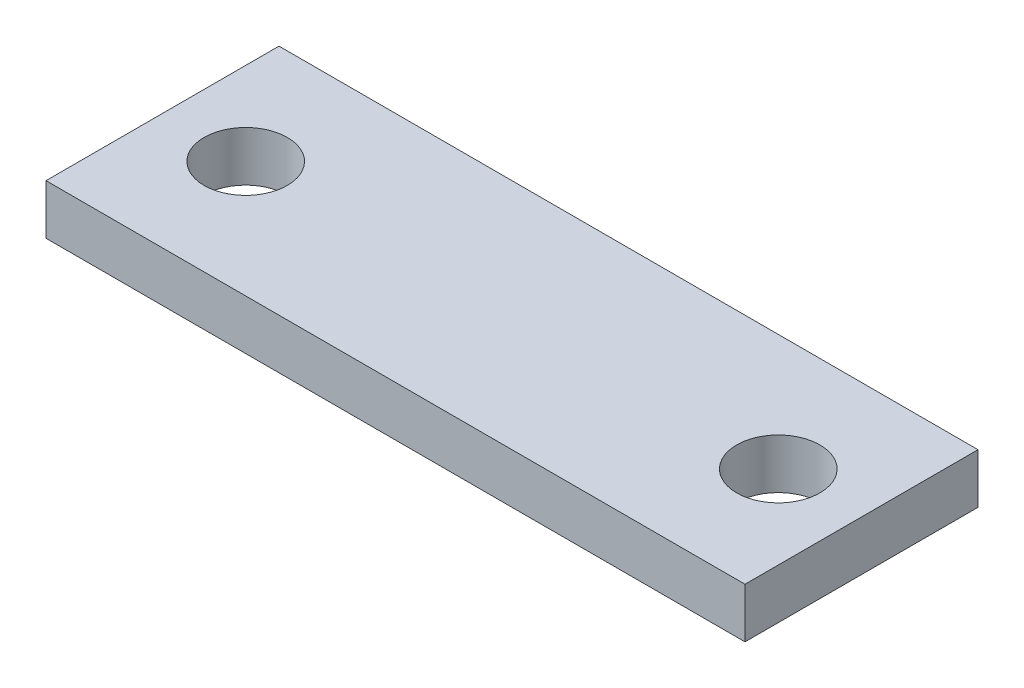
from build123d import *

# Parameters (mm, degrees)
SKETCH_1_W      = 42
SKETCH_1_H      = 14
SKETCH_1_R      = 2.5
EXTRUDE_1_DEPTH = 3


with BuildPart() as part:
    # 草图1 → 凸台-拉伸1 (new body)
    with BuildSketch(Plane(origin=(0, 0, 0), x_dir=(1, 0, 0), z_dir=(0, 1, 0))):
        with Locations((-0.44, 5.533333333)):
            Rectangle(SKETCH_1_W, SKETCH_1_H)
        with Locations((-16.44, 5.533333333)):
            Circle(SKETCH_1_R, mode=Mode.SUBTRACT)
        with Locations((15.56, 5.533333333)):
            Circle(SKETCH_1_R, mode=Mode.SUBTRACT)
    extrude(amount=EXTRUDE_1_DEPTH)


solid = part.part
